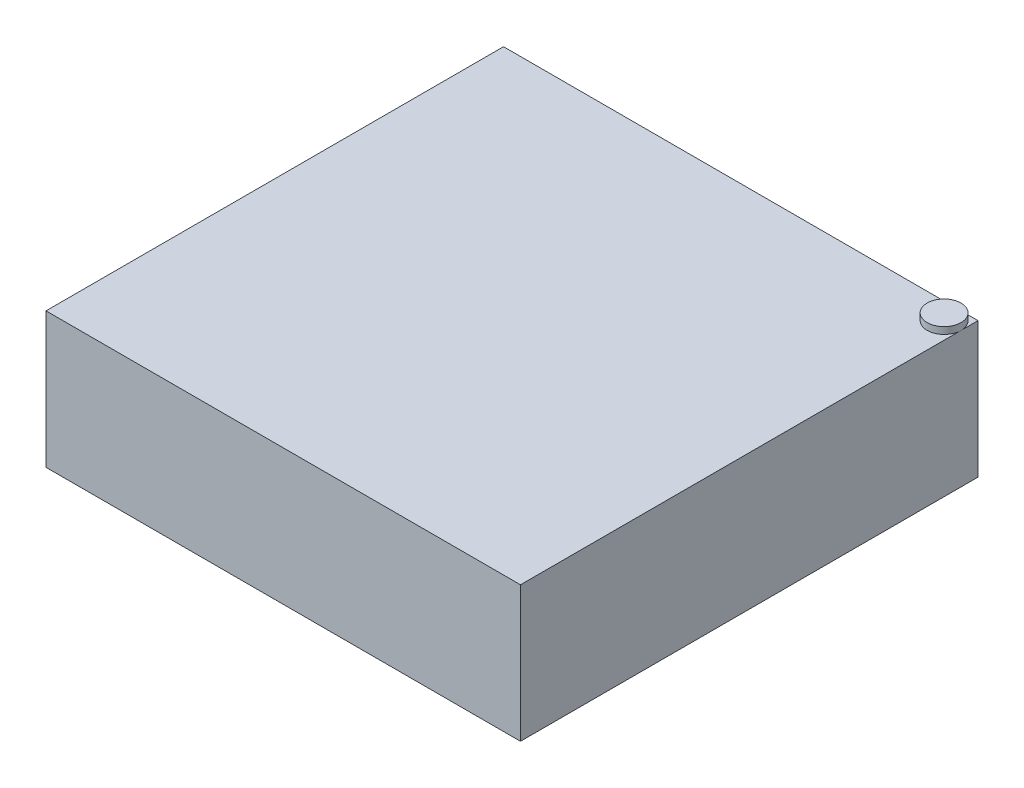
from build123d import *

# Parameters (mm, degrees)
SKETCH1_W           = 177.8
SKETCH1_H           = 171.45
BOSS_EXTRUDE1_DEPTH = 50.8
SKETCH2_R           = 6.35
BOSS_EXTRUDE2_DEPTH = 2.54


with BuildPart() as part:
    # Sketch1 → Boss-Extrude1 (new body)
    with BuildSketch(Plane(origin=(0, 0, 0), x_dir=(1, 0, 0), z_dir=(0, 1, 0))):
        Rectangle(SKETCH1_W, SKETCH1_H)
    extrude(amount=BOSS_EXTRUDE1_DEPTH)

    # Sketch2 → Boss-Extrude2 (add)
    with BuildSketch(Plane(origin=(0, 50.8, 0), x_dir=(1, 0, 0), z_dir=(0, 1, 0))):
        with Locations((82.55, 79.375)):
            Circle(SKETCH2_R)
    extrude(amount=BOSS_EXTRUDE2_DEPTH)


solid = part.part
